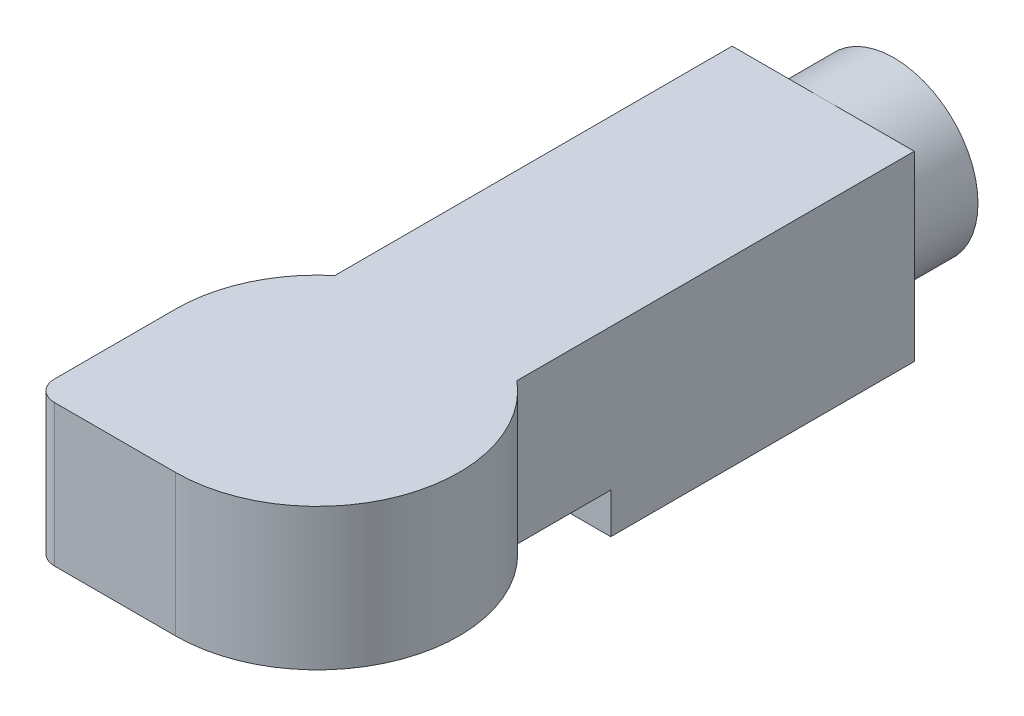
from build123d import *

# Parameters (mm, degrees)
SKETCH2_W           = 90
SKETCH2_H           = 150
BOSS_EXTRUDE1_DEPTH = 20
BOSS_EXTRUDE2_DEPTH = 70
FILLET1_R           = 10
SKETCH4_R           = 41.5
BOSS_EXTRUDE3_DEPTH = 35


with BuildPart() as part:
    # Sketch2 → Boss-Extrude1 (new body)
    with BuildSketch(Plane(origin=(0, 0, 0), x_dir=(1, 0, 0), z_dir=(0, 1, 0))):
        Rectangle(SKETCH2_W, SKETCH2_H)
    extrude(amount=BOSS_EXTRUDE1_DEPTH)

    # Sketch3 → Boss-Extrude2 (add)
    with BuildSketch(Plane(origin=(0, 20, 0), x_dir=(1, 0, 0), z_dir=(0, 1, 0))):
        with BuildLine():
            Line((-45, 75), (45, 75))
            Line((45, 75), (45, -121.380973526))
            ThreePointArc((45, -121.380973526), (65.777396776, -198.944395449), (0, -245))
            Line((0, -245), (-70, -245))
            Line((-70, -245), (-70, -175))
            ThreePointArc((-70, -175), (-63.442887702, -145.419601085), (-45, -121.380973526))
            Line((-45, -121.380973526), (-45, 75))
        make_face()
    extrude(amount=BOSS_EXTRUDE2_DEPTH)

    # Fillet1
    fillet1_edges = [part.edges().sort_by_distance(p)[0] for p in [
        (-70, 55, 245),
    ]]
    fillet(fillet1_edges, radius=FILLET1_R)

    # Sketch4 → Boss-Extrude3 (add)
    with BuildSketch(Plane(origin=(0, 0, -75), x_dir=(-1, 0, 0), z_dir=(0, 0, -1))):
        with Locations((0, 48.5)):
            Circle(SKETCH4_R)
    extrude(amount=BOSS_EXTRUDE3_DEPTH)


solid = part.part
